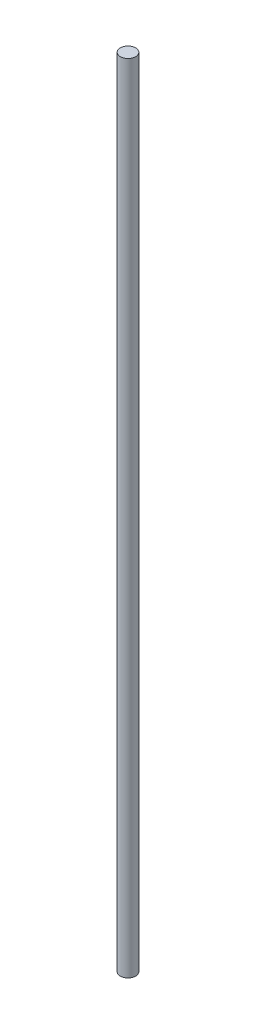
from build123d import *

# Parameters (mm, degrees)
SKETCH1_R           = 4.75
BOSS_EXTRUDE1_DEPTH = 494


with BuildPart() as part:
    # Sketch1 → Boss-Extrude1 (new body)
    with BuildSketch(Plane(origin=(0, 0, 0), x_dir=(1, 0, 0), z_dir=(0, 1, 0))):
        Circle(SKETCH1_R)
    extrude(amount=BOSS_EXTRUDE1_DEPTH)


solid = part.part
